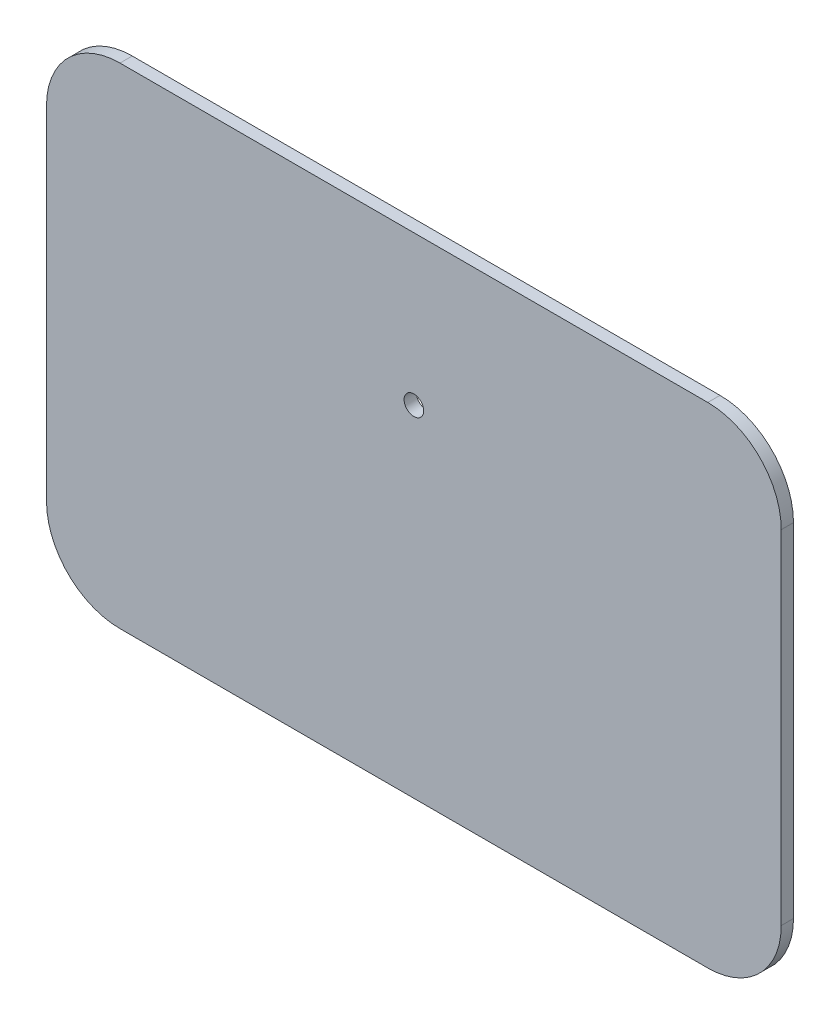
from build123d import *

# Parameters (mm, degrees)
CROQUIS1_R              = 4.05
CROQUIS1_R_2            = 10
CROQUIS1_R_3            = 2
SALIENTE_EXTRUIR1_DEPTH = 5
CROQUIS4_R              = 4
CORTAR_EXTRUIR2_DEPTH   = 10


with BuildPart() as part:
    # Croquis1 → Saliente-Extruir1 (new body)
    with BuildSketch(Plane.XY):
        with BuildLine():
            Line((-152.758258368, 86.1622498), (-152.758258368, -53.8377502))
            ThreePointArc((-152.758258368, -53.8377502), (-143.971461803, -75.050953636), (-122.758258368, -83.8377502))
            Line((-122.758258368, -83.8377502), (117.241741632, -83.8377502))
            ThreePointArc((117.241741632, -83.8377502), (138.454945068, -75.050953636), (147.241741632, -53.8377502))
            Line((147.241741632, -53.8377502), (147.241741632, 86.1622498))
            ThreePointArc((147.241741632, 86.1622498), (138.454945068, 107.375453235), (117.241741632, 116.1622498))
            Line((117.241741632, 116.1622498), (-122.758258368, 116.1622498))
            ThreePointArc((-122.758258368, 116.1622498), (-143.971461803, 107.375453235), (-152.758258368, 86.1622498))
        make_face()
        with Locations((80.390042053, 52.003668375)):
            Circle(CROQUIS1_R, mode=Mode.SUBTRACT)
        with Locations((14.450042053, 52.003668375)):
            Circle(CROQUIS1_R_2, mode=Mode.SUBTRACT)
        with Locations((-1.609957947, 104.003668375)):
            Circle(CROQUIS1_R_3, mode=Mode.SUBTRACT)
        with Locations((102.390042053, 104.003668375)):
            Circle(CROQUIS1_R_3, mode=Mode.SUBTRACT)
        with Locations((52.390042053, 0.003668375)):
            Circle(CROQUIS1_R_3, mode=Mode.SUBTRACT)
        with Locations((-1.609957947, 0.003668375)):
            Circle(CROQUIS1_R_3, mode=Mode.SUBTRACT)
        with Locations((-1.609957947, 104.003668375)):
            Circle(CROQUIS1_R_3)
        with Locations((102.390042053, 104.003668375)):
            Circle(CROQUIS1_R_3)
        with Locations((52.390042053, 0.003668375)):
            Circle(CROQUIS1_R_3)
        with Locations((-1.609957947, 0.003668375)):
            Circle(CROQUIS1_R_3)
        with Locations((14.450042053, 52.003668375)):
            Circle(CROQUIS1_R_2)
        with Locations((80.390042053, 52.003668375)):
            Circle(CROQUIS1_R)
    extrude(amount=SALIENTE_EXTRUIR1_DEPTH)

    # Croquis4 → Cortar-Extruir2 (cut)
    with BuildSketch(Plane(origin=(0, 0, 0), x_dir=(-1, 0, 0), z_dir=(0, 0, -1))):
        with Locations((2.758258368, 55.1622498)):
            Circle(CROQUIS4_R)
    extrude(amount=-CORTAR_EXTRUIR2_DEPTH, mode=Mode.SUBTRACT)


solid = part.part
